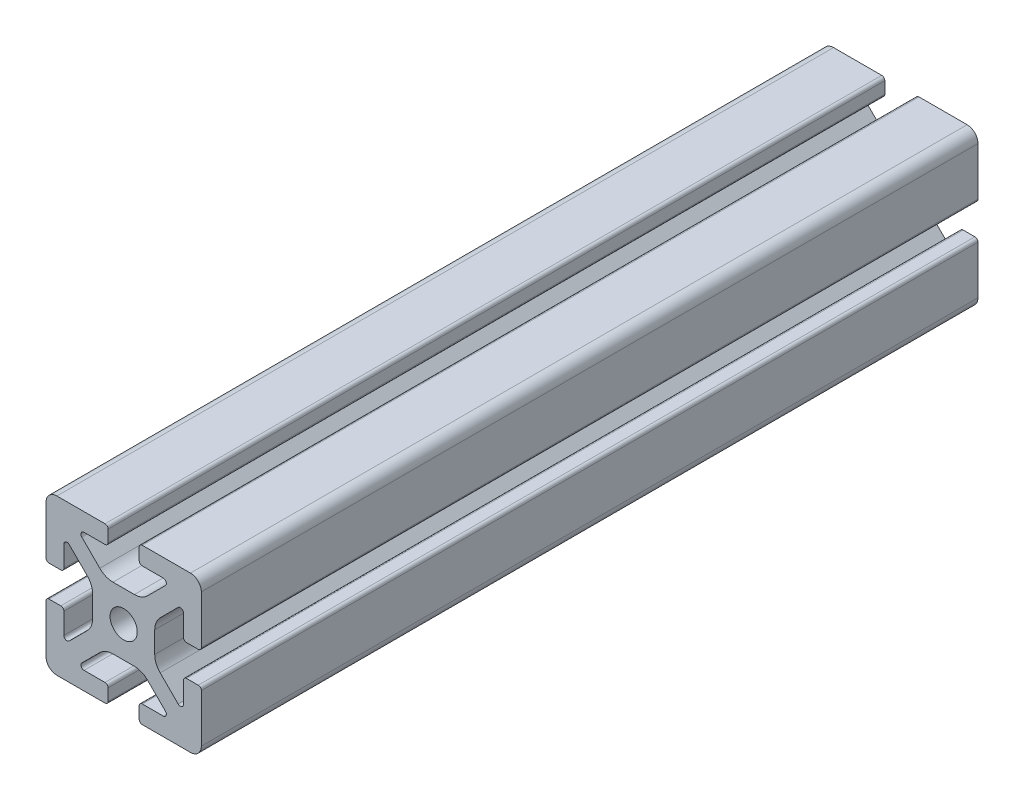
from build123d import *

# Parameters (mm, degrees)
BOSS_EXTRUDE1_DEPTH = 100


with BuildPart() as part:
    # Sketch4 → Boss-Extrude1 (new body, symmetric)
    with BuildSketch(Plane.XY):
        with BuildLine():
            Line((4.8, -20), (17.2, -20))
            ThreePointArc((17.2, -20), (19.179898987, -19.179898987), (20, -17.2))
            Line((20, -17.2), (20, -4.8))
            ThreePointArc((20, -4.8), (19.765685425, -4.234314575), (19.2, -4))
            Line((19.2, -4), (16.190663761, -4))
            ThreePointArc((16.190663761, -4), (15.624978336, -4.234314575), (15.390663761, -4.8))
            Line((15.390663761, -4.8), (15.390663761, -10.2))
            ThreePointArc((15.390663761, -10.2), (14.896810507, -10.939103626), (14.024978336, -10.765685425))
            Line((14.024978336, -10.765685425), (9.40588745, -6.146594539))
            ThreePointArc((9.40588745, -6.146594539), (8.365378244, -4.589362465), (8, -2.752481989))
            Line((8, -2.752481989), (8, 0))
            Line((8, 0), (3.5, 0))
            ThreePointArc((3.5, 0), (2.474873734, -2.474873734), (0, -3.5))
            Line((0, -3.5), (0, -8))
            Line((0, -8), (2.752481989, -8))
            ThreePointArc((2.752481989, -8), (4.589362465, -8.365378244), (6.146594539, -9.40588745))
            Line((6.146594539, -9.40588745), (10.765685425, -14.024978336))
            ThreePointArc((10.765685425, -14.024978336), (10.939103626, -14.896810507), (10.2, -15.390663761))
            Line((10.2, -15.390663761), (4.8, -15.390663761))
            ThreePointArc((4.8, -15.390663761), (4.234314575, -15.624978336), (4, -16.190663761))
            Line((4, -16.190663761), (4, -19.2))
            ThreePointArc((4, -19.2), (4.234314575, -19.765685425), (4.8, -20))
        make_face()
    extrude(amount=BOSS_EXTRUDE1_DEPTH, both=True)

    # Mirror1: part across plane


with BuildPart() as part_1:
    add(part.part)
    add(part.part.mirror(Plane(origin=(0, 0, 0), x_dir=(0, 0, 1), z_dir=(1, 0, 0))))

    # Mirror2: part across plane


with BuildPart() as part_2:
    add(part_1.part)
    add(part_1.part.mirror(Plane.ZX))


solid = part_2.part
